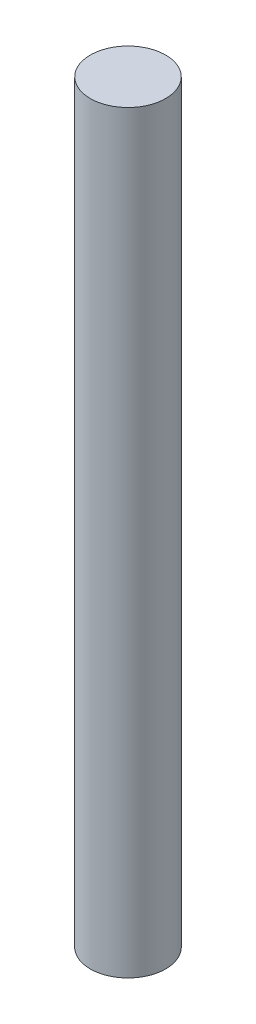
from build123d import *

# Parameters (mm, degrees)
SKETCH1_R           = 7.5
BOSS_EXTRUDE1_DEPTH = 150


with BuildPart() as part:
    # Sketch1 → Boss-Extrude1 (new body)
    with BuildSketch(Plane(origin=(0, 0, 0), x_dir=(1, 0, 0), z_dir=(0, 1, 0))):
        Circle(SKETCH1_R)
    extrude(amount=BOSS_EXTRUDE1_DEPTH)


solid = part.part
